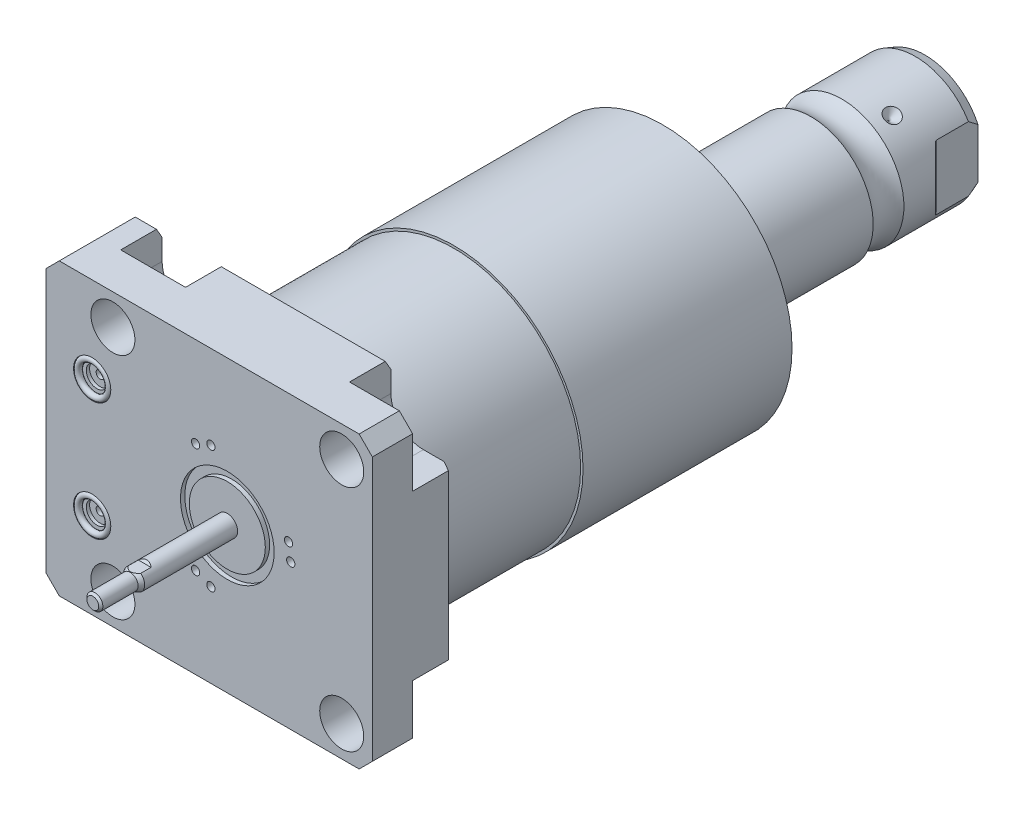
from build123d import *

# Parameters (mm, degrees)
SKETCH1_W               = 100
SKETCH1_H               = 88.9
EXTRUDE1_DEPTH          = 25.019
HOLE1_D                 = 13.487
CUT_EXTRUDE2_DEPTH      = 12.7
SKETCH6_R               = 5.7023
CUT_EXTRUDE3_DEPTH      = 1.4478
SKETCH7_R               = 3.2512
CUT_EXTRUDE4_DEPTH      = 1.016
SKETCH8_R               = 1.2446
CUT_EXTRUDE5_DEPTH      = 11.9888
SKETCH9_R               = 0.9271
CHAMFER1_SIZE           = 4.064
CHAMFER2_SIZE           = 3.0226
CHAMFER2_SIZE2          = 1.745098924
CIRPATTERN1_COUNT       = 3
CUT_EXTRUDE8_DEPTH      = 45.45
CUT_EXTRUDE8_DEPTH_BACK = 45.45
CUT_EXTRUDE9_DEPTH      = 3.81000762
SKETCH37_W              = 1.320802642
SKETCH37_H              = 2.70510541
SKETCH38_R              = 1.27000254
CUT_EXTRUDE10_DEPTH     = 7.62001524


with BuildPart() as part:
    # Sketch1 → Extrude1 (new body)
    with BuildSketch(Plane.XY):
        with Locations((-5.55, 0)):
            Rectangle(SKETCH1_W, SKETCH1_H)
    extrude(amount=EXTRUDE1_DEPTH)

    # Hole1 (through all)
    with Locations(Plane(origin=(0, 0, 0), x_dir=(-1, 0, 0), z_dir=(0, 0, -1))):
        with Locations((-35.052, -35.052), (-35.052, 35.052), (35.052, 35.052), (35.052, -35.052)):
            Hole(HOLE1_D / 2)

    # Sketch3 → Cut-Extrude2 (cut)
    with BuildSketch(Plane(origin=(0, 0, 0), x_dir=(-1, 0, 0), z_dir=(0, 0, -1))):
        with BuildLine():
            Line((-35.052, -25.1205), (-44.45, -25.1205))
            Line((-44.45, -25.1205), (-44.45, -44.45))
            Line((-44.45, -44.45), (-25.1205, -44.45))
            Line((-25.1205, -44.45), (-25.1205, -35.052))
            ThreePointArc((-25.1205, -35.052), (-28.029369003, -28.029369003), (-35.052, -25.1205))
        make_face()
        with BuildLine():
            Line((-44.45, 25.1205), (-44.45, 44.45))
            Line((-44.45, 44.45), (-25.1205, 44.45))
            Line((-25.1205, 44.45), (-25.1205, 35.052))
            ThreePointArc((-25.1205, 35.052), (-28.029369003, 28.029369003), (-35.052, 25.1205))
            Line((-35.052, 25.1205), (-44.45, 25.1205))
        make_face()
        with BuildLine():
            Line((25.1205, 44.45), (25.1205, 35.052))
            ThreePointArc((25.1205, 35.052), (35.052, 25.1205), (44.9835, 35.052))
            Line((44.9835, 35.052), (44.9835, 44.45))
            Line((44.9835, 44.45), (25.1205, 44.45))
        make_face()
        with BuildLine():
            Line((44.9835, -44.45), (25.1205, -44.45))
            Line((25.1205, -44.45), (25.1205, -35.052))
            ThreePointArc((25.1205, -35.052), (35.052, -25.1205), (44.9835, -35.052))
            Line((44.9835, -35.052), (44.9835, -44.45))
        make_face()
    extrude(amount=-CUT_EXTRUDE2_DEPTH, mode=Mode.SUBTRACT)

    # Sketch23 → Cut-Revolve5 (revolve, cut)
    with BuildSketch(Plane.XY.offset(12.014), mode=Mode.PRIVATE) as cut_revolve5_sk:
        Polygon((-55.55, -23.749), (-55.296, -23.749), (-55.296, -19.6596), (-54.5848, -18.9484), (-41.1228, -18.9484), (-41.1228, -13.0048), (-55.55, -13.0048), align=None)
    cut_revolve5 = revolve(cut_revolve5_sk.sketch.rotate(Axis((-11.939660979, -13.0048, 12.014), (-1, 0, 0)), 180), axis=Axis((-11.939660979, -13.0048, 12.014), (-1, 0, 0)), mode=Mode.SUBTRACT)  # turned: the seam where the file's is

    # Mirror1: Cut-Revolve5 across plane
    add(cut_revolve5.mirror(Plane.ZX), mode=Mode.SUBTRACT)

    # Sketch6 → Cut-Extrude3 (cut)
    with BuildSketch(Plane.XY.offset(25.019)):
        with Locations((-41.402, -18.11)):
            Circle(SKETCH6_R)
        with Locations((-41.402, 18.11)):
            Circle(SKETCH6_R)
    extrude(amount=-CUT_EXTRUDE3_DEPTH, mode=Mode.SUBTRACT)

    # Sketch7 → Cut-Extrude4 (cut)
    with BuildSketch(Plane.XY.offset(23.5712)):
        with Locations((-41.402, 18.11)):
            Circle(SKETCH7_R)
        with Locations((-41.402, -18.11)):
            Circle(SKETCH7_R)
    extrude(amount=-CUT_EXTRUDE4_DEPTH, mode=Mode.SUBTRACT)

    # Sketch8 → Cut-Extrude5 (cut)
    with BuildSketch(Plane.XY.offset(22.5552)):
        with Locations((-41.402, 18.11)):
            Circle(SKETCH8_R)
        with Locations((-41.402, -18.11)):
            Circle(SKETCH8_R)
    extrude(amount=-CUT_EXTRUDE5_DEPTH, mode=Mode.SUBTRACT)

    # Chamfer1
    chamfer1_edges = [part.edges().sort_by_distance(p)[0] for p in [
        (-55.55, 44.45, 12.5095),
        (44.45, 44.45, 18.8595),
        (44.45, -44.45, 18.8595),
        (-55.55, -44.45, 12.5095),
    ]]
    chamfer(chamfer1_edges, length=CHAMFER1_SIZE)

    # Chamfer2
    chamfer2_edges = [part.edges().sort_by_distance(p)[0] for p in [
        (-48.23475, -44.45, 0),
        (44.45, 0, 0),
        (0, 44.45, 0),
        (-48.23475, 44.45, 0),
        (0, -44.45, 0),
    ]]
    chamfer2_side = [part.faces().sort_by_distance(p)[0] for p in [
        (-6.590555374, 0, 0),
    ]]
    chamfer(chamfer2_edges, length=CHAMFER2_SIZE, length2=CHAMFER2_SIZE2, reference=chamfer2_side[0])

    # Sketch24 → Revolve4 (revolve)
    with BuildSketch(Plane(origin=(0, 0, 0), x_dir=(0, 0, -1), z_dir=(1, 0, 0)), mode=Mode.PRIVATE) as revolve4_sk:
        Polygon((0, 0), (0, 38.786), (44.45, 38.786), (44.45, 39.5225), (108.48388753, 39.5225), (112.268, 25.4), (112.268, 0), align=None)
    revolve(revolve4_sk.sketch.rotate(Axis((0, 0, 0), (0, 0, -1)), 90), axis=Axis((0, 0, 0), (0, 0, -1)))  # turned: the seam where the file's is

    # Sketch17 → Revolve3 (revolve)
    with BuildSketch(Plane(origin=(0, 0, 0), x_dir=(0, 0, -1), z_dir=(1, 0, 0)), mode=Mode.PRIVATE) as revolve3_sk:
        with BuildLine():
            Line((112.268, 0), (112.268, -19.05))
            Line((112.268, -19.05), (153.81490643, -19.05))
            ThreePointArc((153.81490643, -19.05), (158.522, -17.5006), (163.22909357, -19.05))
            Line((163.22909357, -19.05), (185.77599416, -19.05))
            Line((185.77599416, -19.05), (188.697, -17.98684082))
            Line((188.697, -17.98684082), (188.697, 0))
            Line((188.697, 0), (112.268, 0))
        make_face()
    revolve(revolve3_sk.sketch.rotate(Axis((0, 0, -130.8989), (0, 0, 1)), 270), axis=Axis((0, 0, -130.8989), (0, 0, 1)))  # turned: the seam where the file's is

    # Sketch28 → Cut-Revolve6 (revolve, cut)
    with BuildSketch(Plane(origin=(0, 0, 0), x_dir=(1, 0, 0), z_dir=(0, 1, 0)), mode=Mode.PRIVATE) as cut_revolve6_sk:
        Polygon((-19.05, 171.603), (-16.637, 169.19), (-19.05, 169.19), align=None)
    cut_revolve6 = revolve(cut_revolve6_sk.sketch.rotate(Axis((-34.306164512, 0, -169.19), (1, 0, 0)), 180), axis=Axis((-34.306164512, 0, -169.19), (1, 0, 0)), mode=Mode.SUBTRACT)  # turned: the seam where the file's is

    # CirPattern1: Cut-Revolve6 ×3 about axis
    cirpattern1_axis = Axis((0, 0, -130.8989), (0, 0, -1))
    for i in range(1, CIRPATTERN1_COUNT):
        add(cut_revolve6.rotate(cirpattern1_axis, i * 360 / CIRPATTERN1_COUNT), mode=Mode.SUBTRACT)

    # Sketch32 → Hole2 (revolve, cut)
    with BuildSketch(Plane(origin=(0, 0, -188.697), x_dir=(0, 1, 0), z_dir=(1, 0, 0))):
        Polygon((0, 0), (0, 29.566487704), (6.9342, 25.4), (6.9342, 0), align=None)
    revolve(axis=Axis((0, 0, -192.941199587), (0, 0, 1)), mode=Mode.SUBTRACT)

    # Sketch34 → Cut-Extrude8 (cut, two sides)
    with BuildSketch(Plane(origin=(0, 0, 0), x_dir=(0, 0, -1), z_dir=(0, 1, 0))) as cut_extrude8_sk:
        with BuildLine():
            Line((172.912868636, 19.05), (175.458183558, 16.504685078))
            ThreePointArc((175.458183558, 16.504685078), (175.705394643, 16.339503912), (175.997, 16.2815))
            Line((175.997, 16.2815), (188.697, 16.2815))
            Line((188.697, 16.2815), (188.697, 19.05))
            Line((188.697, 19.05), (172.912868636, 19.05))
        make_face()
        with BuildLine():
            Line((188.697, -19.05), (172.912868636, -19.05))
            Line((172.912868636, -19.05), (175.458183558, -16.504685078))
            ThreePointArc((175.458183558, -16.504685078), (175.705394643, -16.339503912), (175.997, -16.2815))
            Line((175.997, -16.2815), (188.697, -16.2815))
            Line((188.697, -16.2815), (188.697, -19.05))
        make_face()
    extrude(amount=CUT_EXTRUDE8_DEPTH, mode=Mode.SUBTRACT)
    extrude(cut_extrude8_sk.sketch, amount=-CUT_EXTRUDE8_DEPTH_BACK, mode=Mode.SUBTRACT)

    # Sketch35 → Revolve5 (revolve)
    with BuildSketch(Plane(origin=(0, 0, 0), x_dir=(0, 0, -1), z_dir=(1, 0, 0)), mode=Mode.PRIVATE) as revolve5_sk:
        Polygon((-25.019, 0), (-25.019, -3.17500635), (-53.511145963, -3.17500635), (-54.78697714, -2.438404877), (-65.58199873, -2.438404877), (-66.217, -1.803403607), (-66.217, 0), align=None)
    revolve(revolve5_sk.sketch.rotate(Axis((0, 0, 1000), (0, 0, -1)), 270), axis=Axis((0, 0, 1000), (0, 0, -1)))  # turned: the seam where the file's is

    # Sketch36 → Cut-Extrude9 (cut, symmetric)
    with BuildSketch(Plane(origin=(0, 0, 0), x_dir=(0, 0, -1), z_dir=(1, 0, 0))):
        Polygon((-49.668866904, -3.17500635), (-50.34196825, -2.501905004), (-66.217, -2.501905004), (-66.217, -3.17500635), align=None)
        Polygon((-49.668866904, 3.17500635), (-50.34196825, 2.501905004), (-66.217, 2.501905004), (-66.217, 3.17500635), align=None)
    extrude(amount=CUT_EXTRUDE9_DEPTH, both=True, mode=Mode.SUBTRACT)

    # Sketch37 → Cut-Revolve7 (revolve, cut)
    with BuildSketch(Plane(origin=(0, 0, 0), x_dir=(0, 0, -1), z_dir=(1, 0, 0)), mode=Mode.PRIVATE) as cut_revolve7_sk:
        with Locations((-24.358598679, -12.998475997)):
            Rectangle(SKETCH37_W, SKETCH37_H)
    revolve(cut_revolve7_sk.sketch.rotate(Axis((0, 0, 1000), (0, 0, -1)), 270), axis=Axis((0, 0, 1000), (0, 0, -1)), mode=Mode.SUBTRACT)  # turned: the seam where the file's is

    # Sketch38 → Cut-Extrude10 (cut)
    with BuildSketch(Plane.XY.offset(25.019)):
        with Locations((19.431038862, 0)):
            Circle(SKETCH38_R)
        with Locations((18.768942269, 5.029122924)):
            Circle(SKETCH38_R)
        with Locations(Location((-5.029122924, 18.768942269, 0), (0, 0, 180))):  # turned: the seam where the file's is
            Circle(SKETCH38_R)
        with Locations(Location((-9.715519431, 16.827773276, 0), (0, 0, 180))):  # turned: the seam where the file's is
            Circle(SKETCH38_R)
        with Locations((-9.715519431, -16.827773276)):
            Circle(SKETCH38_R)
        with Locations((-5.029122924, -18.768942269)):
            Circle(SKETCH38_R)
    extrude(amount=-CUT_EXTRUDE10_DEPTH, mode=Mode.SUBTRACT)


with BuildPart() as body_2:
    # Sketch9 → Revolve1 (revolve)
    with BuildSketch(Plane(origin=(-41.656, 18.11, 23.5712), x_dir=(1, 0, 0), z_dir=(0, 1, 0))):
        with Locations((5.0292, -0.9271)):
            Circle(SKETCH9_R)
    revolve(axis=Axis((-41.402, 18.11, 25.51811), (0, 0, -1)))


with BuildPart() as body_3:
    # Mirror2: mirrored copy
    add(body_2.part.mirror(Plane.ZX))


solid = Compound([part.part, body_2.part, body_3.part])
